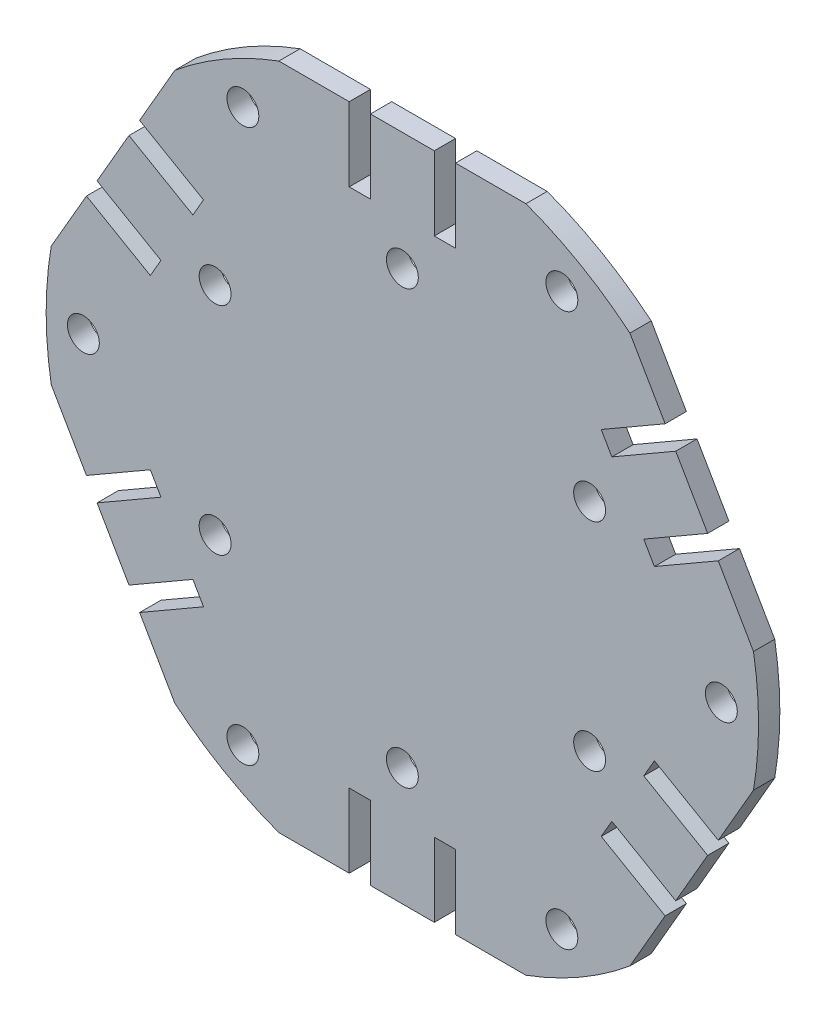
from build123d import *

# Parameters (mm, degrees)
MODEL_R             = 1.5
BOSS_EXTRUDE1_DEPTH = 2


with BuildPart() as part:
    # Model → Boss-Extrude1 (new body)
    with BuildSketch(Plane.XY):
        with BuildLine():
            Line((-18.701410202, -16.570766906), (-19.701410202, -14.838716098))
            Line((-19.701410202, -14.838716098), (-25.711054778, -18.308386013))
            Line((-25.711054778, -18.308386013), (-28.711054778, -13.11223359))
            Line((-28.711054778, -13.11223359), (-22.701410202, -9.642563676))
            Line((-22.701410202, -9.642563676), (-23.701410202, -7.910512868))
            Line((-23.701410202, -7.910512868), (-29.711054778, -11.380182782))
            Line((-29.711054778, -11.380182782), (-33.02041498, -5.648202773))
            ThreePointArc((-33.02041498, -5.648202773), (-33.5, 0), (-33.02041498, 5.648202773))
            Line((-33.02041498, 5.648202773), (-29.711054778, 11.380182782))
            Line((-29.711054778, 11.380182782), (-23.701410202, 7.910512868))
            Line((-23.701410202, 7.910512868), (-22.701410202, 9.642563676))
            Line((-22.701410202, 9.642563676), (-28.711054778, 13.11223359))
            Line((-28.711054778, 13.11223359), (-25.711054778, 18.308386013))
            Line((-25.711054778, 18.308386013), (-19.701410202, 14.838716098))
            Line((-19.701410202, 14.838716098), (-18.701410202, 16.570766906))
            Line((-18.701410202, 16.570766906), (-24.711054778, 20.04043682))
            Line((-24.711054778, 20.04043682), (-21.401694577, 25.77241683))
            ThreePointArc((-21.401694577, 25.77241683), (-16.75, 29.011851027), (-11.618720403, 31.420619602))
            Line((-11.618720403, 31.420619602), (-5, 31.420619602))
            Line((-5, 31.420619602), (-5, 24.481279774))
            Line((-5, 24.481279774), (-3, 24.481279774))
            Line((-3, 24.481279774), (-3, 31.420619602))
            Line((-3, 31.420619602), (3, 31.420619602))
            Line((3, 31.420619602), (3, 24.481279774))
            Line((3, 24.481279774), (5, 24.481279774))
            Line((5, 24.481279774), (5, 31.420619602))
            Line((5, 31.420619602), (11.618720403, 31.420619602))
            ThreePointArc((11.618720403, 31.420619602), (16.75, 29.011851027), (21.401694577, 25.77241683))
            Line((21.401694577, 25.77241683), (24.711054778, 20.04043682))
            Line((24.711054778, 20.04043682), (18.701410202, 16.570766906))
            Line((18.701410202, 16.570766906), (19.701410202, 14.838716098))
            Line((19.701410202, 14.838716098), (25.711054778, 18.308386013))
            Line((25.711054778, 18.308386013), (28.711054778, 13.11223359))
            Line((28.711054778, 13.11223359), (22.701410202, 9.642563676))
            Line((22.701410202, 9.642563676), (23.701410202, 7.910512868))
            Line((23.701410202, 7.910512868), (29.711054778, 11.380182782))
            Line((29.711054778, 11.380182782), (33.02041498, 5.648202773))
            ThreePointArc((33.02041498, 5.648202773), (33.5, 0), (33.02041498, -5.648202773))
            Line((33.02041498, -5.648202773), (29.711054778, -11.380182782))
            Line((29.711054778, -11.380182782), (23.701410202, -7.910512868))
            Line((23.701410202, -7.910512868), (22.701410202, -9.642563676))
            Line((22.701410202, -9.642563676), (28.711054778, -13.11223359))
            Line((28.711054778, -13.11223359), (25.711054778, -18.308386013))
            Line((25.711054778, -18.308386013), (19.701410202, -14.838716098))
            Line((19.701410202, -14.838716098), (18.701410202, -16.570766906))
            Line((18.701410202, -16.570766906), (24.711054778, -20.04043682))
            Line((24.711054778, -20.04043682), (21.401694577, -25.77241683))
            ThreePointArc((21.401694577, -25.77241683), (16.75, -29.011851027), (11.618720403, -31.420619602))
            Line((11.618720403, -31.420619602), (5, -31.420619602))
            Line((5, -31.420619602), (5, -24.481279774))
            Line((5, -24.481279774), (3, -24.481279774))
            Line((3, -24.481279774), (3, -31.420619602))
            Line((3, -31.420619602), (-3, -31.420619602))
            Line((-3, -31.420619602), (-3, -24.481279774))
            Line((-3, -24.481279774), (-5, -24.481279774))
            Line((-5, -24.481279774), (-5, -31.420619602))
            Line((-5, -31.420619602), (-11.618720403, -31.420619602))
            ThreePointArc((-11.618720403, -31.420619602), (-16.75, -29.011851027), (-21.401694577, -25.77241683))
            Line((-21.401694577, -25.77241683), (-24.711054778, -20.04043682))
            Line((-24.711054778, -20.04043682), (-18.701410202, -16.570766906))
        make_face()
        with Locations((-17.610482102, -10.167416582)):
            Circle(MODEL_R, mode=Mode.SUBTRACT)
        with Locations((-17.610482102, 10.167416582)):
            Circle(MODEL_R, mode=Mode.SUBTRACT)
        with Locations((0, -20.334833165)):
            Circle(MODEL_R, mode=Mode.SUBTRACT)
        with Locations((17.610482102, -10.167416582)):
            Circle(MODEL_R, mode=Mode.SUBTRACT)
        with Locations((0, 20.334833165)):
            Circle(MODEL_R, mode=Mode.SUBTRACT)
        with Locations((-30, 0)):
            Circle(MODEL_R, mode=Mode.SUBTRACT)
        with Locations((-15, -25.980762114)):
            Circle(MODEL_R, mode=Mode.SUBTRACT)
        with Locations((15, 25.980762114)):
            Circle(MODEL_R, mode=Mode.SUBTRACT)
        with Locations((-15, 25.980762114)):
            Circle(MODEL_R, mode=Mode.SUBTRACT)
        with Locations((15, -25.980762114)):
            Circle(MODEL_R, mode=Mode.SUBTRACT)
        with Locations((30, 0)):
            Circle(MODEL_R, mode=Mode.SUBTRACT)
        with Locations((17.610482102, 10.167416582)):
            Circle(MODEL_R, mode=Mode.SUBTRACT)
    extrude(amount=BOSS_EXTRUDE1_DEPTH)


solid = part.part
